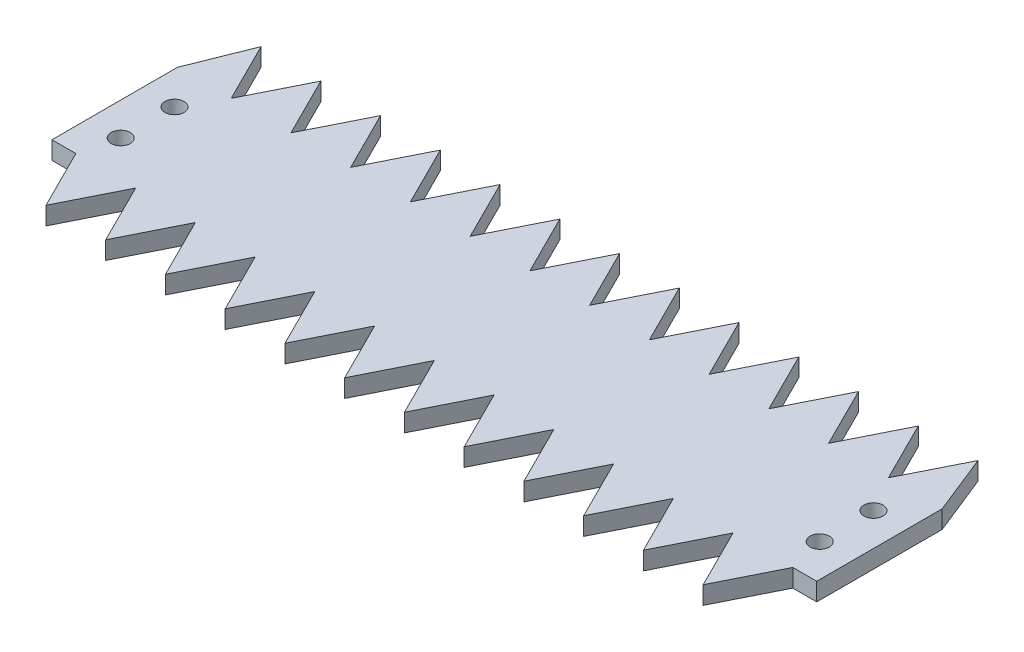
from build123d import *

# Parameters (mm, degrees)
SKETCH1_W               = 128
SKETCH1_H               = 41
BOSS_EXTRUDE1_DEPTH     = 3
CUT_EXTRUDE2_START      = -4
CUT_EXTRUDE2_DEPTH      = 5
LPATTERN3_COUNT         = 12
LPATTERN3_PITCH         = 10
CUT_EXTRUDE3_START      = -4
CUT_EXTRUDE3_DEPTH      = 5
LPATTERN5_COUNT         = 12
LPATTERN5_PITCH         = 10
CUT_EXTRUDE4_START      = -4
SKETCH6_R               = 1.6
CUT_EXTRUDE4_DEPTH      = 5
MIRROR3_START           = -4
MIRROR3_COPY_1_SKETCH_R = 1.6
MIRROR3_COPY_1_DEPTH    = 5
CUT_EXTRUDE5_START      = -4
CUT_EXTRUDE5_DEPTH      = 5
CUT_EXTRUDE6_START      = -4
SKETCH8_W               = 4
SKETCH8_H               = 10
CUT_EXTRUDE6_DEPTH      = 5


with BuildPart() as part:
    # Sketch1 → Boss-Extrude1 (new body)
    with BuildSketch(Plane(origin=(0, 0, 0), x_dir=(1, 0, 0), z_dir=(0, 1, 0))):
        Rectangle(SKETCH1_W, SKETCH1_H)
    extrude(amount=BOSS_EXTRUDE1_DEPTH)

    # Sketch2 → Cut-Extrude2 (cut)
    with BuildSketch(Plane(origin=(0, 3, 0), x_dir=(1, 0, 0), z_dir=(0, 1, 0)).offset(CUT_EXTRUDE2_START)):
        Polygon((-60, 20.5), (-55, 10.5), (-50, 20.5), align=None)
    cut_extrude2 = extrude(amount=CUT_EXTRUDE2_DEPTH, mode=Mode.SUBTRACT)

    # LPattern3: Cut-Extrude2 ×12
    with Locations(*[(i * LPATTERN3_PITCH, 0, 0) for i in range(1, LPATTERN3_COUNT)]):
        add(cut_extrude2, mode=Mode.SUBTRACT)

    # Sketch5 → Cut-Extrude3 (cut)
    with BuildSketch(Plane(origin=(0, 3, 0), x_dir=(1, 0, 0), z_dir=(0, 1, 0)).offset(CUT_EXTRUDE3_START)):
        Polygon((-55, -20.5), (-60, -10.5), (-60, -20.5), align=None)
        Polygon((-50, -10.5), (-55, -20.5), (-50, -20.5), align=None)
    cut_extrude3 = extrude(amount=CUT_EXTRUDE3_DEPTH, mode=Mode.SUBTRACT)

    # LPattern5: Cut-Extrude3 ×12
    with Locations(*[(i * LPATTERN5_PITCH, 0, 0) for i in range(1, LPATTERN5_COUNT)]):
        add(cut_extrude3, mode=Mode.SUBTRACT)

    # Sketch6 → Cut-Extrude4 (cut)
    with BuildSketch(Plane(origin=(0, 3, 0), x_dir=(1, 0, 0), z_dir=(0, 1, 0)).offset(CUT_EXTRUDE4_START)):
        with Locations((-58.5, 4.5)):
            Circle(SKETCH6_R)
    cut_extrude4 = extrude(amount=CUT_EXTRUDE4_DEPTH, mode=Mode.SUBTRACT)

    # Mirror2: Cut-Extrude4 across plane
    add(cut_extrude4.mirror(Plane(origin=(0, 0, 0), x_dir=(0, 0, 1), z_dir=(1, 0, 0))), mode=Mode.SUBTRACT)

    # Mirror3: Cut-Extrude4 across plane
    add(cut_extrude4.mirror(Plane.XY), mode=Mode.SUBTRACT)

    # Mirror3 copy 1 sketch → Mirror3 copy 1 (cut)
    with BuildSketch(Plane(origin=(0, 3, 0), x_dir=(-1, 0, 0), z_dir=(0, 1, 0)).offset(MIRROR3_START)):
        with Locations((-58.5, 4.5)):
            Circle(MIRROR3_COPY_1_SKETCH_R)
    extrude(amount=MIRROR3_COPY_1_DEPTH, mode=Mode.SUBTRACT)

    # Sketch7 → Cut-Extrude5 (cut)
    with BuildSketch(Plane(origin=(0, 3, 0), x_dir=(1, 0, 0), z_dir=(0, 1, 0)).offset(CUT_EXTRUDE5_START)):
        Polygon((-60, 20.5), (-64, 10.5), (-64, 20.5), align=None)
    cut_extrude5 = extrude(amount=CUT_EXTRUDE5_DEPTH, mode=Mode.SUBTRACT)

    # Mirror4: Cut-Extrude5 across plane
    add(cut_extrude5.mirror(Plane(origin=(0, 0, 0), x_dir=(0, 0, 1), z_dir=(1, 0, 0))), mode=Mode.SUBTRACT)

    # Sketch8 → Cut-Extrude6 (cut)
    with BuildSketch(Plane(origin=(0, 3, 0), x_dir=(1, 0, 0), z_dir=(0, 1, 0)).offset(CUT_EXTRUDE6_START)):
        with Locations((-62, -15.5)):
            Rectangle(SKETCH8_W, SKETCH8_H)
    cut_extrude6 = extrude(amount=CUT_EXTRUDE6_DEPTH, mode=Mode.SUBTRACT)

    # Mirror5: Cut-Extrude6 across plane
    add(cut_extrude6.mirror(Plane(origin=(0, 0, 0), x_dir=(0, 0, 1), z_dir=(1, 0, 0))), mode=Mode.SUBTRACT)


solid = part.part
